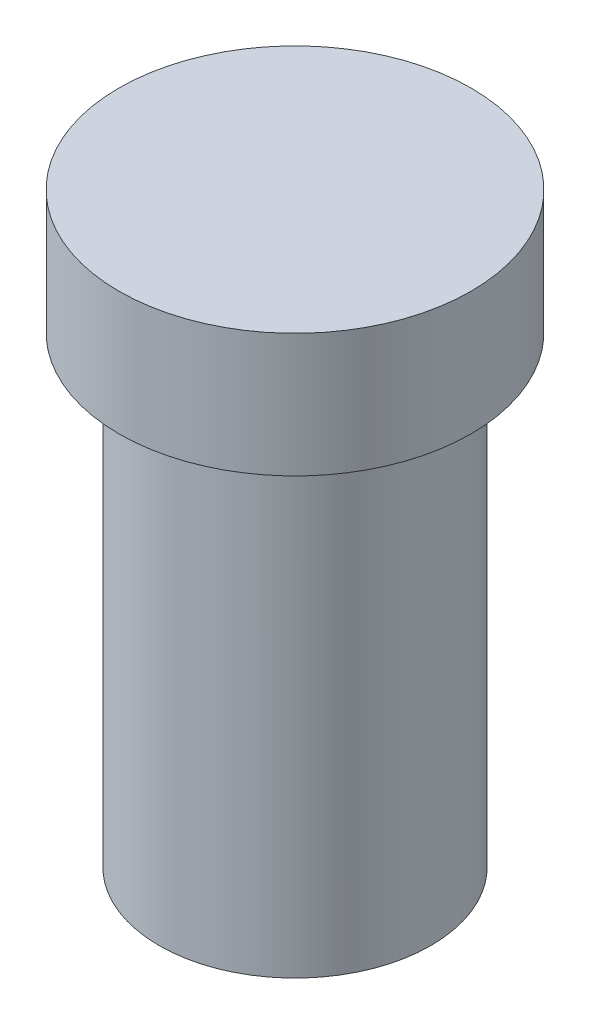
from build123d import *

# Parameters (mm, degrees)
SKETCH1_R           = 28.5
BOSS_EXTRUDE1_DEPTH = 20
SKETCH2_R           = 22
BOSS_EXTRUDE2_DEPTH = 75


with BuildPart() as part:
    # Sketch1 → Boss-Extrude1 (new body)
    with BuildSketch(Plane(origin=(0, 0, 0), x_dir=(1, 0, 0), z_dir=(0, 1, 0))):
        with Locations(Location((0, 0, 0), (0, 0, 270))):  # turned: the seam where the file's is
            Circle(SKETCH1_R)
    extrude(amount=-BOSS_EXTRUDE1_DEPTH)

    # Sketch2 → Boss-Extrude2 (add)
    with BuildSketch(Plane.XZ.offset(20)):
        with Locations(Location((0, 0, 0), (0, 0, 90))):  # turned: the seam where the file's is
            Circle(SKETCH2_R)
    extrude(amount=BOSS_EXTRUDE2_DEPTH)


solid = part.part
